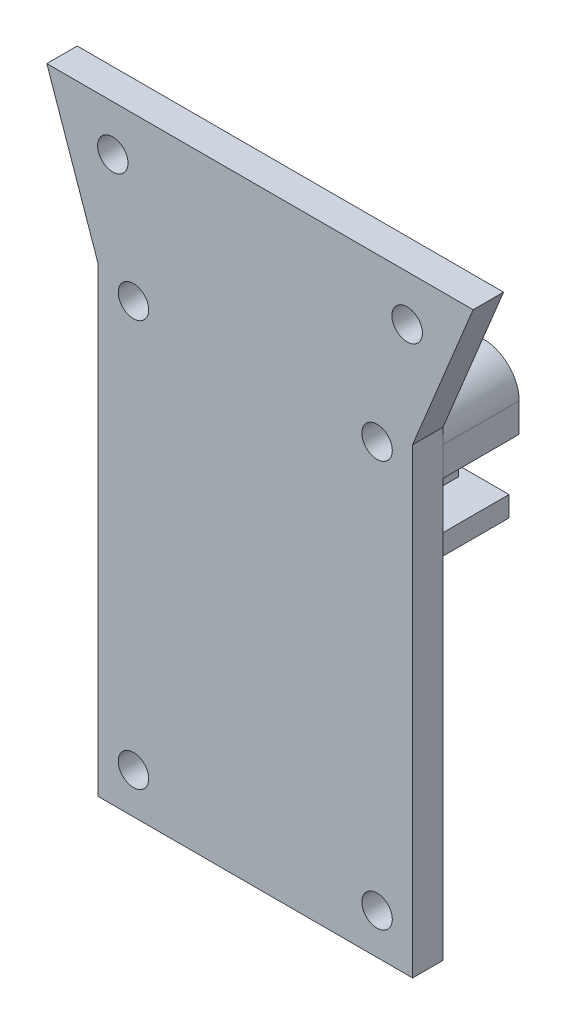
from build123d import *

# Parameters (mm, degrees)
SKETCH1_R           = 1.5
BOSS_EXTRUDE1_DEPTH = 3
SKETCH2_R           = 2.5
BOSS_EXTRUDE2_DEPTH = 1.5
SKETCH5_R           = 2.5
BOSS_EXTRUDE5_DEPTH = 6
SKETCH9_W           = 12
SKETCH9_H           = 8
CUT_EXTRUDE2_DEPTH  = 6
SKETCH11_W          = 8
SKETCH11_H          = 4
CUT_EXTRUDE4_DEPTH  = 2
SKETCH13_W          = 5
SKETCH13_H          = 13
CUT_EXTRUDE7_DEPTH  = 1.5
SKETCH16_W          = 2
SKETCH16_H          = 2
CUT_EXTRUDE9_DEPTH  = 39.820836522
BOSS_EXTRUDE6_DEPTH = 5
SKETCH20_W          = 3.5
SKETCH20_H          = 8
CUT_EXTRUDE10_DEPTH = 2
BOSS_EXTRUDE7_DEPTH = 2


with BuildPart() as part:
    # Sketch1 → Boss-Extrude1 (new body)
    with BuildSketch(Plane.XY):
        Polygon((0, 0), (31, 0), (31, 45.5), (36.963007518, 60), (-5.036992482, 60), (0, 45.5), align=None)
        with Locations((30.463007518, 55.5)):
            Circle(SKETCH1_R, mode=Mode.SUBTRACT)
        with Locations((27.5, 44)):
            Circle(SKETCH1_R, mode=Mode.SUBTRACT)
        with Locations((27.5, 4)):
            Circle(SKETCH1_R, mode=Mode.SUBTRACT)
        with Locations((3.5, 4)):
            Circle(SKETCH1_R, mode=Mode.SUBTRACT)
        with Locations((3.5, 44)):
            Circle(SKETCH1_R, mode=Mode.SUBTRACT)
        with Locations((1.463007518, 55.5)):
            Circle(SKETCH1_R, mode=Mode.SUBTRACT)
    extrude(amount=BOSS_EXTRUDE1_DEPTH)


with BuildPart() as body_2:
    # Sketch2 → Boss-Extrude2 (new body)
    with BuildSketch(Plane(origin=(0, 0, 0), x_dir=(-1, 0, 0), z_dir=(0, 0, -1))):
        with BuildLine():
            Line((0, 24.5), (0, 44))
            ThreePointArc((0, 44), (-3.750643519, 47.491013868), (-6.964101615, 43.5))
            Line((-6.964101615, 43.5), (-24.035898385, 43.5))
            ThreePointArc((-24.035898385, 43.5), (-27.249356481, 47.491013868), (-31, 44))
            Line((-31, 44), (-31, 41.136038969))
            Line((-31, 41.136038969), (-25, 35.136038969))
            Line((-25, 35.136038969), (-25, 28.5))
            Line((-25, 28.5), (-18, 28.5))
            Line((-18, 28.5), (-18, 24.5))
            Line((-18, 24.5), (0, 24.5))
        make_face()
        with Locations((-27.5, 44)):
            Circle(SKETCH2_R, mode=Mode.SUBTRACT)
        with Locations((-3.5, 44)):
            Circle(SKETCH2_R, mode=Mode.SUBTRACT)
    extrude(amount=BOSS_EXTRUDE2_DEPTH)

    # Sketch5 → Boss-Extrude5 (add)
    with BuildSketch(Plane(origin=(0, 0, -1.5), x_dir=(-1, 0, 0), z_dir=(0, 0, -1))):
        with BuildLine():
            Line((-6.964101615, 43.5), (-24.035898385, 43.5))
            ThreePointArc((-24.035898385, 43.5), (-27.249356481, 47.491013868), (-31, 44))
            Line((-31, 44), (-31, 41.136038969))
            Line((-31, 41.136038969), (-25, 35.136038969))
            Line((-25, 35.136038969), (-25, 28.5))
            Line((-25, 28.5), (-18, 28.5))
            Line((-18, 28.5), (-18, 24.5))
            Line((-18, 24.5), (0, 24.5))
            Line((0, 24.5), (0, 44))
            ThreePointArc((0, 44), (-3.750643519, 47.491013868), (-6.964101615, 43.5))
        make_face()
        with Locations((-27.5, 44)):
            Circle(SKETCH5_R, mode=Mode.SUBTRACT)
        with BuildLine():
            Line((-23, 41.5), (-5.5, 41.5))
            Line((-5.5, 41.5), (-5.5, 42.5))
            ThreePointArc((-5.5, 42.5), (-3.146446609, 46.474873734), (-2, 42))
            Line((-2, 42), (-2, 26.5))
            Line((-2, 26.5), (-16, 26.5))
            Line((-16, 26.5), (-16, 30.5))
            Line((-16, 30.5), (-23, 30.5))
            Line((-23, 30.5), (-23, 41.5))
        make_face(mode=Mode.SUBTRACT)
    extrude(amount=BOSS_EXTRUDE5_DEPTH)

    # Sketch9 → Cut-Extrude2 (cut)
    with BuildSketch(Plane.XZ.offset(-24.5)):
        with Locations((16, -4)):
            Rectangle(SKETCH9_W, SKETCH9_H)
    extrude(amount=-CUT_EXTRUDE2_DEPTH, mode=Mode.SUBTRACT)

    # Sketch11 → Cut-Extrude4 (cut)
    with BuildSketch(Plane(origin=(25, 0, 0), x_dir=(0, 0, -1), z_dir=(1, 0, 0))):
        with Locations((8, 32.5)):
            Rectangle(SKETCH11_W, SKETCH11_H)
    extrude(amount=-CUT_EXTRUDE4_DEPTH, mode=Mode.SUBTRACT)

    # Sketch13 → Cut-Extrude7 (cut)
    with BuildSketch(Plane.XY):
        with Locations((15.5, 37)):
            Rectangle(SKETCH13_W, SKETCH13_H)
    extrude(amount=-CUT_EXTRUDE7_DEPTH, mode=Mode.SUBTRACT)

    # Sketch16 → Cut-Extrude9 (cut, through all)
    with BuildSketch(Plane(origin=(-5.068019485, 5.068019485, 0), x_dir=(0, 0, -1), z_dir=(0.707106781, -0.707106781, 0))):
        with Locations((6.5, 47.608387387)):
            Rectangle(SKETCH16_W, SKETCH16_H)
    extrude(amount=-CUT_EXTRUDE9_DEPTH, mode=Mode.SUBTRACT)

    # Sketch19 → Boss-Extrude6 (add)
    with BuildSketch(Plane(origin=(0, 0, -7.5), x_dir=(-1, 0, 0), z_dir=(0, 0, -1))):
        Polygon((-18, 28.5), (-25, 28.5), (-25, 30.5), (-16, 30.5), (-16, 26.5), (0, 26.5), (0, 24.5), (-18, 24.5), align=None)
    extrude(amount=BOSS_EXTRUDE6_DEPTH)

    # Sketch20 → Cut-Extrude10 (cut)
    with BuildSketch(Plane.ZY):
        with Locations((-5.75, 30.5)):
            Rectangle(SKETCH20_W, SKETCH20_H)
    extrude(amount=-CUT_EXTRUDE10_DEPTH, mode=Mode.SUBTRACT)

    # Sketch21 → Boss-Extrude7 (add)
    with BuildSketch(Plane.XZ.offset(-28.5)):
        Polygon((22, -5), (19.5, -7.5), (22, -7.5), align=None)
    extrude(amount=-BOSS_EXTRUDE7_DEPTH)


solid = Compound([part.part, body_2.part])
